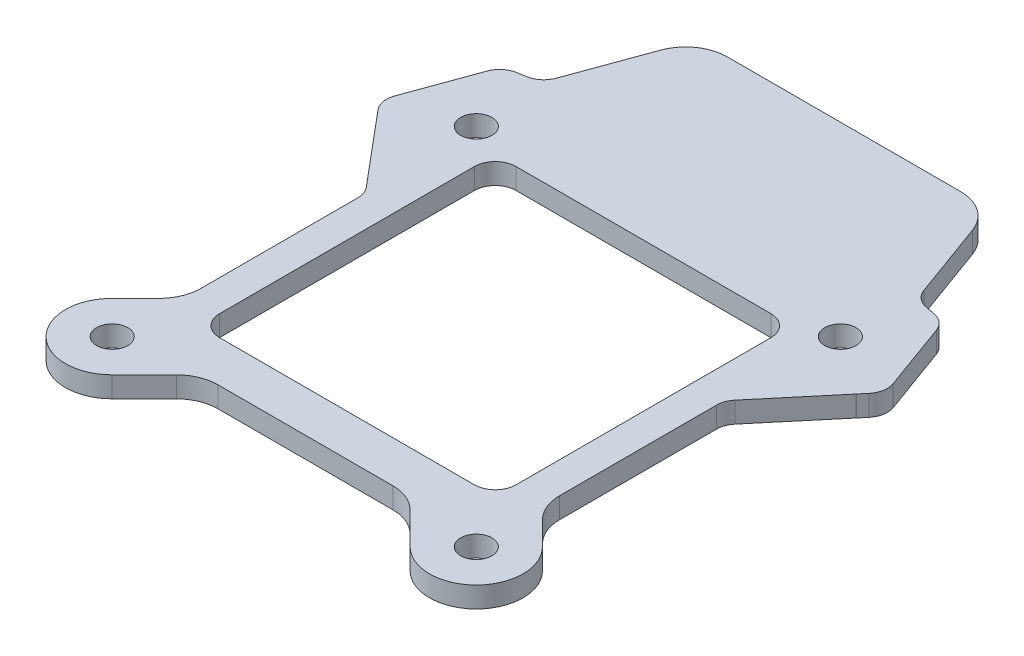
from build123d import *

# Parameters (mm, degrees)
SKETCH1_R           = 1.5
SKETCH1_R_2         = 1.500000075
SKETCH1_R_3         = 1.499999926
BOSS_EXTRUDE1_DEPTH = 2


with BuildPart() as part:
    # Sketch1 → Boss-Extrude1 (new body)
    with BuildSketch(Plane(origin=(0, 0, 0), x_dir=(1, 0, 0), z_dir=(0, 1, 0))):
        with BuildLine():
            Line((16.641623692, -1.328817394), (16.641623692, -16.412584868))
            ThreePointArc((16.641623692, -16.412584868), (16.946106169, -17.943318476), (17.813197688, -19.241011527))
            Line((17.813197688, -19.241011527), (20.073605121, -21.501420823))
            ThreePointArc((20.073605121, -21.501420823), (20.073603258, -27.865380806), (13.709643275, -27.865378943))
            Line((13.709643275, -27.865378943), (10.626761594, -24.782500056))
            ThreePointArc((10.626761594, -24.782500056), (9.329068113, -23.915408358), (7.798334003, -23.610926059))
            Line((7.798334003, -23.610926059), (-9.015085756, -23.610926059))
            ThreePointArc((-9.015085756, -23.610926059), (-10.545819865, -23.915408358), (-11.843513346, -24.782500056))
            Line((-11.843513346, -24.782500056), (-14.926395028, -27.865378943))
            ThreePointArc((-14.926395028, -27.865378943), (-21.290355011, -27.865380806), (-21.290356874, -21.501420823))
            Line((-21.290356874, -21.501420823), (-19.029949441, -19.241011527))
            ThreePointArc((-19.029949441, -19.241011527), (-18.162857921, -17.943318476), (-17.858375444, -16.412584868))
            Line((-17.858375444, -16.412584868), (-17.858375444, -1.328817394))
            ThreePointArc((-17.858375444, -1.328817394), (-17.9789903, -0.644777024), (-18.326286807, -0.043242064))
            Line((-18.326286807, -0.043242064), (-23.644334286, 6.294557068))
            ThreePointArc((-23.644334286, 6.294557068), (-23.650520639, 6.302037606), (-23.656743228, 6.309488031))
            Line((-23.656743228, 6.309488031), (-24.213413357, 6.972902629))
            ThreePointArc((-24.213413357, 6.972902629), (-24.650941114, 7.911183978), (-24.560709133, 8.942523214))
            Line((-24.560709133, 8.942523214), (-22.191124617, 15.452907595))
            ThreePointArc((-22.191124617, 15.452907595), (-21.597313109, 16.300951983), (-20.659035652, 16.738475475))
            Line((-20.659035652, 16.738475475), (-19.806167691, 16.888857993))
            ThreePointArc((-19.806167691, 16.888857993), (-18.867887285, 17.3263878), (-18.274078726, 18.174440774))
            Line((-18.274078726, 18.174440774), (-15.59413655, 25.537521753))
            ThreePointArc((-15.59413655, 25.537521753), (-14.129671055, 27.446048523), (-11.835365205, 28.169439348))
            Line((-11.835365205, 28.169439348), (10.618613453, 28.169439348))
            ThreePointArc((10.618613453, 28.169439348), (12.912919302, 27.446048523), (14.377384798, 25.537521753))
            Line((14.377384798, 25.537521753), (17.057326973, 18.174440774))
            ThreePointArc((17.057326973, 18.174440774), (17.651135533, 17.3263878), (18.589415939, 16.888857993))
            Line((18.589415939, 16.888857993), (19.4422839, 16.738475475))
            ThreePointArc((19.4422839, 16.738475475), (20.380561357, 16.300951983), (20.974372865, 15.452907595))
            Line((20.974372865, 15.452907595), (23.34395738, 8.942523214))
            ThreePointArc((23.34395738, 8.942523214), (23.434189362, 7.911183978), (22.996661604, 6.972902629))
            Line((22.996661604, 6.972902629), (22.439991475, 6.309488031))
            ThreePointArc((22.439991475, 6.309488031), (22.433768887, 6.302037606), (22.427582533, 6.294557068))
            Line((22.427582533, 6.294557068), (17.109535054, -0.043242064))
            ThreePointArc((17.109535054, -0.043242064), (16.762238548, -0.644777024), (16.641623692, -1.328817394))
        make_face()
        with Locations((-18.108375876, 10.316600984)):
            Circle(SKETCH1_R, mode=Mode.SUBTRACT)
        with Locations((-18.108375951, -24.683399883)):
            Circle(SKETCH1_R_2, mode=Mode.SUBTRACT)
        with Locations((16.891624198, -24.683399883)):
            Circle(SKETCH1_R_3, mode=Mode.SUBTRACT)
        with Locations((16.891624124, 10.316600984)):
            Circle(SKETCH1_R, mode=Mode.SUBTRACT)
        with BuildLine():
            Line((-14.858375884, -17.61092135), (-14.858375884, 6.889076146))
            ThreePointArc((-14.858375884, 6.889076146), (-14.272588129, 8.303287628), (-12.858375556, 8.889072749))
            Line((-12.858375556, 8.889072749), (11.641623803, 8.889072749))
            ThreePointArc((11.641623803, 8.889072749), (13.055836377, 8.303287628), (13.641624131, 6.889076146))
            Line((13.641624131, 6.889076146), (13.641624131, -17.61092135))
            ThreePointArc((13.641624131, -17.61092135), (13.055839011, -19.025137649), (11.641623803, -19.610925403))
            Line((11.641623803, -19.610925403), (-12.858375556, -19.610925403))
            ThreePointArc((-12.858375556, -19.610925403), (-14.272590763, -19.025137649), (-14.858375884, -17.61092135))
        make_face(mode=Mode.SUBTRACT)
    extrude(amount=BOSS_EXTRUDE1_DEPTH)


solid = part.part
